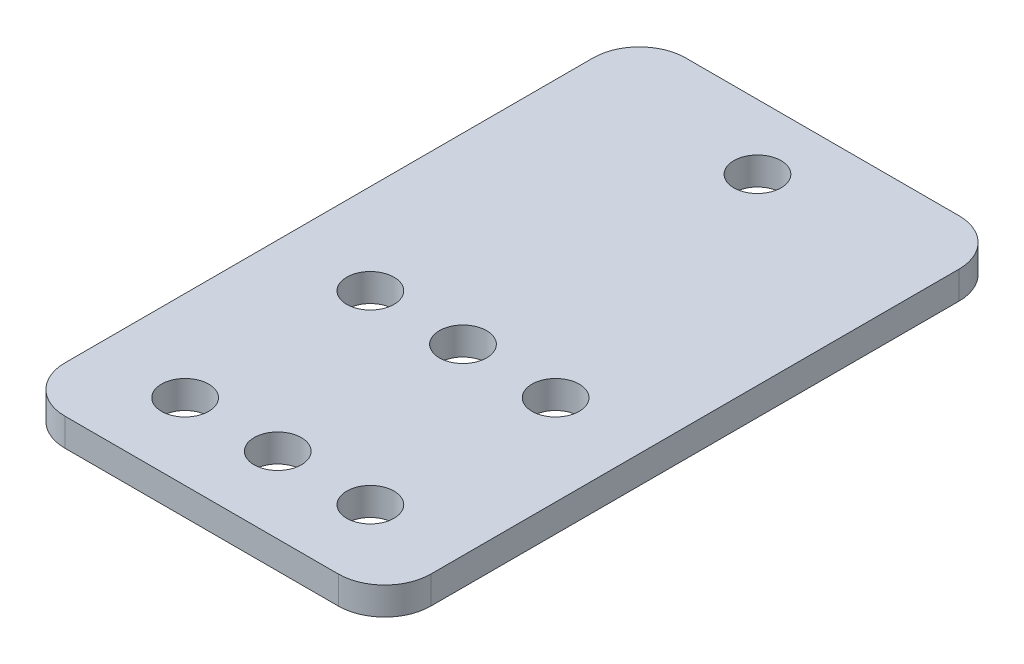
from build123d import *

# Parameters (mm, degrees)
SKETCH1_R           = 2.55
BOSS_EXTRUDE1_DEPTH = 3


with BuildPart() as part:
    # Sketch1 → Boss-Extrude1 (new body)
    with BuildSketch(Plane(origin=(0, 0, 0), x_dir=(1, 0, 0), z_dir=(0, 1, 0))):
        with BuildLine():
            Line((14.75, -33.5), (-14.75, -33.5))
            ThreePointArc((-14.75, -33.5), (-18.285533906, -32.035533906), (-19.75, -28.5))
            Line((-19.75, -28.5), (-19.75, 28.5))
            ThreePointArc((-19.75, 28.5), (-18.285533906, 32.035533906), (-14.75, 33.5))
            Line((-14.75, 33.5), (14.75, 33.5))
            ThreePointArc((14.75, 33.5), (18.285533906, 32.035533906), (19.75, 28.5))
            Line((19.75, 28.5), (19.75, -28.5))
            ThreePointArc((19.75, -28.5), (18.285533906, -32.035533906), (14.75, -33.5))
        make_face()
        with Locations((0, 26.5)):
            Circle(SKETCH1_R, mode=Mode.SUBTRACT)
        with Locations((10, -25.29)):
            Circle(SKETCH1_R, mode=Mode.SUBTRACT)
        with Locations((10, -5.29)):
            Circle(SKETCH1_R, mode=Mode.SUBTRACT)
        with Locations((0, -25.29)):
            Circle(SKETCH1_R, mode=Mode.SUBTRACT)
        with Locations((0, -5.29)):
            Circle(SKETCH1_R, mode=Mode.SUBTRACT)
        with Locations((-10, -25.29)):
            Circle(SKETCH1_R, mode=Mode.SUBTRACT)
        with Locations((-10, -5.29)):
            Circle(SKETCH1_R, mode=Mode.SUBTRACT)
    extrude(amount=BOSS_EXTRUDE1_DEPTH)


solid = part.part
